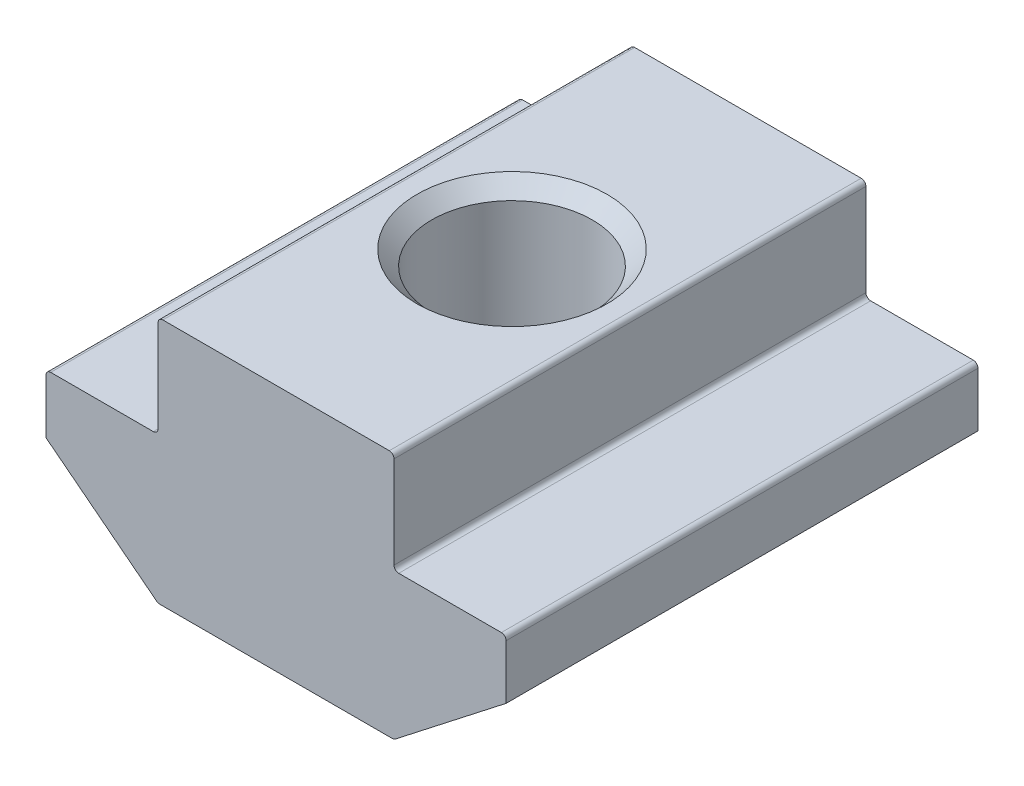
from build123d import *

# Parameters (mm, degrees)
EXTRUDE_1_DEPTH = 10
FILLET_1_R      = 0.2


with BuildPart() as part:
    # Эскиз1 → Бобышка-Вытянуть1 (new body, symmetric)
    with BuildSketch(Plane.XY):
        Polygon((5, 0), (-5, 0), (-5, -4.3), (-9.75, -4.3), (-9.75, -6.8), (-5, -10.5), (5, -10.5), (9.75, -6.8), (9.75, -4.3), (5, -4.3), align=None)
    extrude(amount=EXTRUDE_1_DEPTH, both=True)

    # Эскиз4 → Отверстие обработанное метчиком M83 (revolve, cut)
    with BuildSketch(Plane(origin=(0, 0, 0), x_dir=(0, 0, 1), z_dir=(1, 0, 0))):
        Polygon((0, 0), (0, 10.5), (4.025, 10.5), (3.4, 9.875), (3.4, 0.625), (4.025, 0), align=None)
    revolve(axis=Axis((0, 6.35, 0), (0, -1, 0)), mode=Mode.SUBTRACT)

    # Скругление1
    fillet_1_edges = [part.edges().sort_by_distance(p)[0] for p in [
        (-5, 0, 0),
        (5, 0, 0),
        (5, -4.3, 0),
        (9.75, -4.3, 0),
        (5, -10.5, 0),
        (-5, -10.5, 0),
        (-9.75, -4.3, 0),
        (-5, -4.3, 0),
    ]]
    fillet(fillet_1_edges, radius=FILLET_1_R)


solid = part.part
